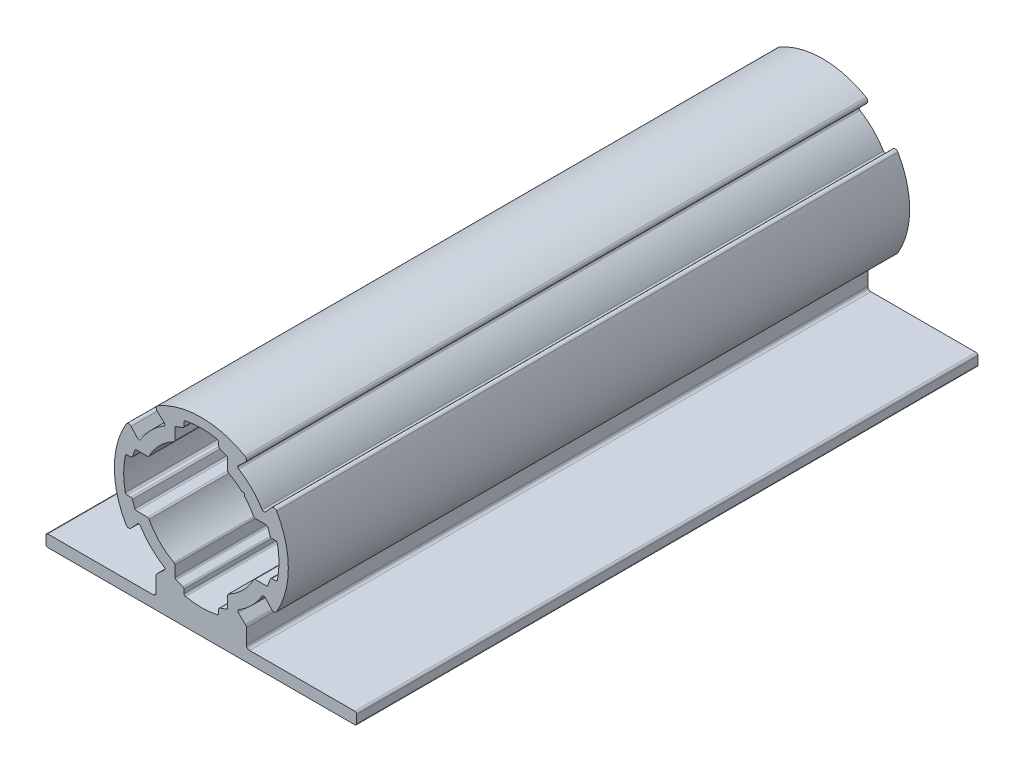
from build123d import *

# Parameters (mm, degrees)
EXTRUDE_1_DEPTH = 100


with BuildPart() as part:
    # Model → 凸台-拉伸1 (new body)
    with BuildSketch(Plane.XY):
        with BuildLine():
            Line((1440.867570561, 579.107478259), (1452.807293918, 579.107478259))
            Line((1452.807293918, 579.107478259), (1457.807293918, 579.107478259))
            ThreePointArc((1457.807293918, 579.107478259), (1458.019425952, 579.019610294), (1458.107293918, 578.807478259))
            Line((1458.107293918, 578.807478259), (1458.107293918, 577.507478259))
            ThreePointArc((1458.107293918, 577.507478259), (1458.019425952, 577.295346225), (1457.807293918, 577.207478259))
            Line((1457.807293918, 577.207478259), (1408.407293918, 577.207478259))
            ThreePointArc((1408.407293918, 577.207478259), (1408.195161884, 577.295346225), (1408.107293918, 577.507478259))
            Line((1408.107293918, 577.507478259), (1408.107293918, 578.807478259))
            ThreePointArc((1408.107293918, 578.807478259), (1408.195161884, 579.019610294), (1408.407293918, 579.107478259))
            Line((1408.407293918, 579.107478259), (1425.347017276, 579.107478259))
            ThreePointArc((1425.347017276, 579.107478259), (1425.700570666, 579.253924869), (1425.847017276, 579.607478259))
            Line((1425.847017276, 579.607478259), (1425.847017276, 582.022074556))
            ThreePointArc((1425.847017276, 582.022074556), (1425.888989436, 582.222600109), (1426.007859266, 582.389459701))
            Line((1426.007859266, 582.389459701), (1427.136441813, 583.431330379))
            ThreePointArc((1427.136441813, 583.431330379), (1427.231524995, 583.680936543), (1427.089921929, 583.907415283))
            ThreePointArc((1427.089921929, 583.907415283), (1424.975565934, 585.575750276), (1423.307230942, 587.69010627))
            ThreePointArc((1423.307230942, 587.69010627), (1423.080752201, 587.831709337), (1422.831146038, 587.736626154))
            Line((1422.831146038, 587.736626154), (1421.789275359, 586.608043608))
            ThreePointArc((1421.789275359, 586.608043608), (1421.366754977, 586.450250809), (1420.989097485, 586.696821001))
            ThreePointArc((1420.989097485, 586.696821001), (1419.107293918, 593.707478259), (1420.989097485, 600.718135518))
            ThreePointArc((1420.989097485, 600.718135518), (1421.366754977, 600.96470571), (1421.789275359, 600.806912911))
            Line((1421.789275359, 600.806912911), (1422.831146038, 599.678330364))
            ThreePointArc((1422.831146038, 599.678330364), (1423.080752201, 599.583247182), (1423.307230942, 599.724850249))
            ThreePointArc((1423.307230942, 599.724850249), (1424.975565934, 601.839206243), (1427.089921929, 603.507541236))
            ThreePointArc((1427.089921929, 603.507541236), (1427.231524995, 603.734019976), (1427.136441813, 603.98362614))
            Line((1427.136441813, 603.98362614), (1426.007859266, 605.025496818))
            ThreePointArc((1426.007859266, 605.025496818), (1425.850066468, 605.448017201), (1426.096636659, 605.825674693))
            ThreePointArc((1426.096636659, 605.825674693), (1433.107293918, 607.707478259), (1440.117951177, 605.825674693))
            ThreePointArc((1440.117951177, 605.825674693), (1440.364521369, 605.448017201), (1440.20672857, 605.025496818))
            Line((1440.20672857, 605.025496818), (1439.078146023, 603.98362614))
            ThreePointArc((1439.078146023, 603.98362614), (1438.983062841, 603.734019976), (1439.124665907, 603.507541236))
            ThreePointArc((1439.124665907, 603.507541236), (1441.239021902, 601.839206243), (1442.907356895, 599.724850249))
            ThreePointArc((1442.907356895, 599.724850249), (1443.133835635, 599.583247182), (1443.383441798, 599.678330364))
            Line((1443.383441798, 599.678330364), (1444.425312477, 600.806912911))
            ThreePointArc((1444.425312477, 600.806912911), (1444.847832859, 600.96470571), (1445.225490352, 600.718135518))
            ThreePointArc((1445.225490352, 600.718135518), (1447.107293918, 593.707478259), (1445.225490352, 586.696821001))
            ThreePointArc((1445.225490352, 586.696821001), (1444.847832859, 586.450250809), (1444.425312477, 586.608043608))
            Line((1444.425312477, 586.608043608), (1443.383441798, 587.736626154))
            ThreePointArc((1443.383441798, 587.736626154), (1443.133835635, 587.831709337), (1442.907356895, 587.69010627))
            ThreePointArc((1442.907356895, 587.69010627), (1441.239021902, 585.575750276), (1439.124665907, 583.907415283))
            ThreePointArc((1439.124665907, 583.907415283), (1438.983062841, 583.680936543), (1439.078146023, 583.431330379))
            Line((1439.078146023, 583.431330379), (1440.20672857, 582.389459701))
            ThreePointArc((1440.20672857, 582.389459701), (1440.325598401, 582.222600109), (1440.367570561, 582.022074556))
            Line((1440.367570561, 582.022074556), (1440.367570561, 579.607478259))
            ThreePointArc((1440.367570561, 579.607478259), (1440.51401717, 579.253924869), (1440.867570561, 579.107478259))
        make_face()
        with BuildLine():
            Line((1421.166188442, 590.907478259), (1421.754066124, 590.907478259))
            ThreePointArc((1421.754066124, 590.907478259), (1421.914408846, 590.857021745), (1422.016963461, 590.723836915))
            Line((1422.016963461, 590.723836915), (1422.411999107, 589.64605289))
            ThreePointArc((1422.411999107, 589.64605289), (1422.514553722, 589.51286806), (1422.674896444, 589.462411545))
            Line((1422.674896444, 589.462411545), (1424.424991887, 589.462411545))
            ThreePointArc((1424.424991887, 589.462411545), (1424.58032957, 589.419063458), (1424.690776643, 589.30154624))
            ThreePointArc((1424.690776643, 589.30154624), (1426.389779497, 586.989963838), (1428.701361899, 585.290960984))
            ThreePointArc((1428.701361899, 585.290960984), (1428.818879117, 585.180513911), (1428.862227204, 585.025176228))
            Line((1428.862227204, 585.025176228), (1428.862227204, 583.275080785))
            ThreePointArc((1428.862227204, 583.275080785), (1428.912683718, 583.114738064), (1429.045868549, 583.012183448))
            Line((1429.045868549, 583.012183448), (1430.123652573, 582.617147802))
            ThreePointArc((1430.123652573, 582.617147802), (1430.256837404, 582.514593187), (1430.307293918, 582.354250466))
            Line((1430.307293918, 582.354250466), (1430.307293918, 581.766372783))
            ThreePointArc((1430.307293918, 581.766372783), (1430.374439218, 581.577220229), (1430.545818508, 581.472739042))
            ThreePointArc((1430.545818508, 581.472739042), (1433.107293918, 581.207478259), (1435.668769328, 581.472739042))
            ThreePointArc((1435.668769328, 581.472739042), (1435.840148618, 581.577220229), (1435.907293918, 581.766372783))
            Line((1435.907293918, 581.766372783), (1435.907293918, 582.354250466))
            ThreePointArc((1435.907293918, 582.354250466), (1435.957750433, 582.514593187), (1436.090935263, 582.617147802))
            Line((1436.090935263, 582.617147802), (1437.168719288, 583.012183448))
            ThreePointArc((1437.168719288, 583.012183448), (1437.301904118, 583.114738064), (1437.352360632, 583.275080785))
            Line((1437.352360632, 583.275080785), (1437.352360632, 585.025176228))
            ThreePointArc((1437.352360632, 585.025176228), (1437.39570872, 585.180513911), (1437.513225937, 585.290960984))
            ThreePointArc((1437.513225937, 585.290960984), (1439.824808339, 586.989963838), (1441.523811193, 589.30154624))
            ThreePointArc((1441.523811193, 589.30154624), (1441.634258267, 589.419063458), (1441.789595949, 589.462411545))
            Line((1441.789595949, 589.462411545), (1443.539691393, 589.462411545))
            ThreePointArc((1443.539691393, 589.462411545), (1443.700034114, 589.51286806), (1443.802588729, 589.64605289))
            Line((1443.802588729, 589.64605289), (1444.197624375, 590.723836915))
            ThreePointArc((1444.197624375, 590.723836915), (1444.300178991, 590.857021745), (1444.460521712, 590.907478259))
            Line((1444.460521712, 590.907478259), (1445.048399395, 590.907478259))
            ThreePointArc((1445.048399395, 590.907478259), (1445.237551948, 590.974623559), (1445.342033136, 591.14600285))
            ThreePointArc((1445.342033136, 591.14600285), (1445.607293918, 593.707478259), (1445.342033136, 596.268953669))
            ThreePointArc((1445.342033136, 596.268953669), (1445.237551948, 596.44033296), (1445.048399395, 596.507478259))
            Line((1445.048399395, 596.507478259), (1444.460521712, 596.507478259))
            ThreePointArc((1444.460521712, 596.507478259), (1444.300178991, 596.557934774), (1444.197624375, 596.691119604))
            Line((1444.197624375, 596.691119604), (1443.802588729, 597.768903629))
            ThreePointArc((1443.802588729, 597.768903629), (1443.700034114, 597.902088459), (1443.539691393, 597.952544974))
            Line((1443.539691393, 597.952544974), (1441.789595949, 597.952544974))
            ThreePointArc((1441.789595949, 597.952544974), (1441.634258267, 597.995893061), (1441.523811193, 598.113410278))
            ThreePointArc((1441.523811193, 598.113410278), (1440.851379085, 599.210127161), (1440.036940374, 600.205939616))
            Line((1440.036940374, 600.205939616), (1440.036940374, 600.637124715))
            Line((1440.036940374, 600.637124715), (1439.605755274, 600.637124715))
            ThreePointArc((1439.605755274, 600.637124715), (1438.609942819, 601.451563426), (1437.513225937, 602.123995535))
            ThreePointArc((1437.513225937, 602.123995535), (1437.39570872, 602.234442608), (1437.352360632, 602.389780291))
            Line((1437.352360632, 602.389780291), (1437.352360632, 604.139875734))
            ThreePointArc((1437.352360632, 604.139875734), (1437.301904118, 604.300218455), (1437.168719288, 604.402773071))
            Line((1437.168719288, 604.402773071), (1436.090935263, 604.797808717))
            ThreePointArc((1436.090935263, 604.797808717), (1435.957750433, 604.900363332), (1435.907293918, 605.060706053))
            Line((1435.907293918, 605.060706053), (1435.907293918, 605.648583736))
            ThreePointArc((1435.907293918, 605.648583736), (1435.840148618, 605.837736289), (1435.668769328, 605.942217477))
            ThreePointArc((1435.668769328, 605.942217477), (1433.107293918, 606.207478259), (1430.545818508, 605.942217477))
            ThreePointArc((1430.545818508, 605.942217477), (1430.374439218, 605.837736289), (1430.307293918, 605.648583736))
            Line((1430.307293918, 605.648583736), (1430.307293918, 605.060706053))
            ThreePointArc((1430.307293918, 605.060706053), (1430.256837404, 604.900363332), (1430.123652573, 604.797808717))
            Line((1430.123652573, 604.797808717), (1429.045868549, 604.402773071))
            ThreePointArc((1429.045868549, 604.402773071), (1428.912683718, 604.300218455), (1428.862227204, 604.139875734))
            Line((1428.862227204, 604.139875734), (1428.862227204, 602.389780291))
            ThreePointArc((1428.862227204, 602.389780291), (1428.818879117, 602.234442608), (1428.701361899, 602.123995535))
            ThreePointArc((1428.701361899, 602.123995535), (1426.389779497, 600.424992681), (1424.690776643, 598.113410278))
            ThreePointArc((1424.690776643, 598.113410278), (1424.58032957, 597.995893061), (1424.424991887, 597.952544974))
            Line((1424.424991887, 597.952544974), (1422.674896444, 597.952544974))
            ThreePointArc((1422.674896444, 597.952544974), (1422.514553722, 597.902088459), (1422.411999107, 597.768903629))
            Line((1422.411999107, 597.768903629), (1422.016963461, 596.691119604))
            ThreePointArc((1422.016963461, 596.691119604), (1421.914408846, 596.557934774), (1421.754066124, 596.507478259))
            Line((1421.754066124, 596.507478259), (1421.166188442, 596.507478259))
            ThreePointArc((1421.166188442, 596.507478259), (1420.977035888, 596.44033296), (1420.8725547, 596.268953669))
            ThreePointArc((1420.8725547, 596.268953669), (1420.607293918, 593.707478259), (1420.8725547, 591.14600285))
            ThreePointArc((1420.8725547, 591.14600285), (1420.977035888, 590.974623559), (1421.166188442, 590.907478259))
        make_face(mode=Mode.SUBTRACT)
    extrude(amount=EXTRUDE_1_DEPTH)


solid = part.part
